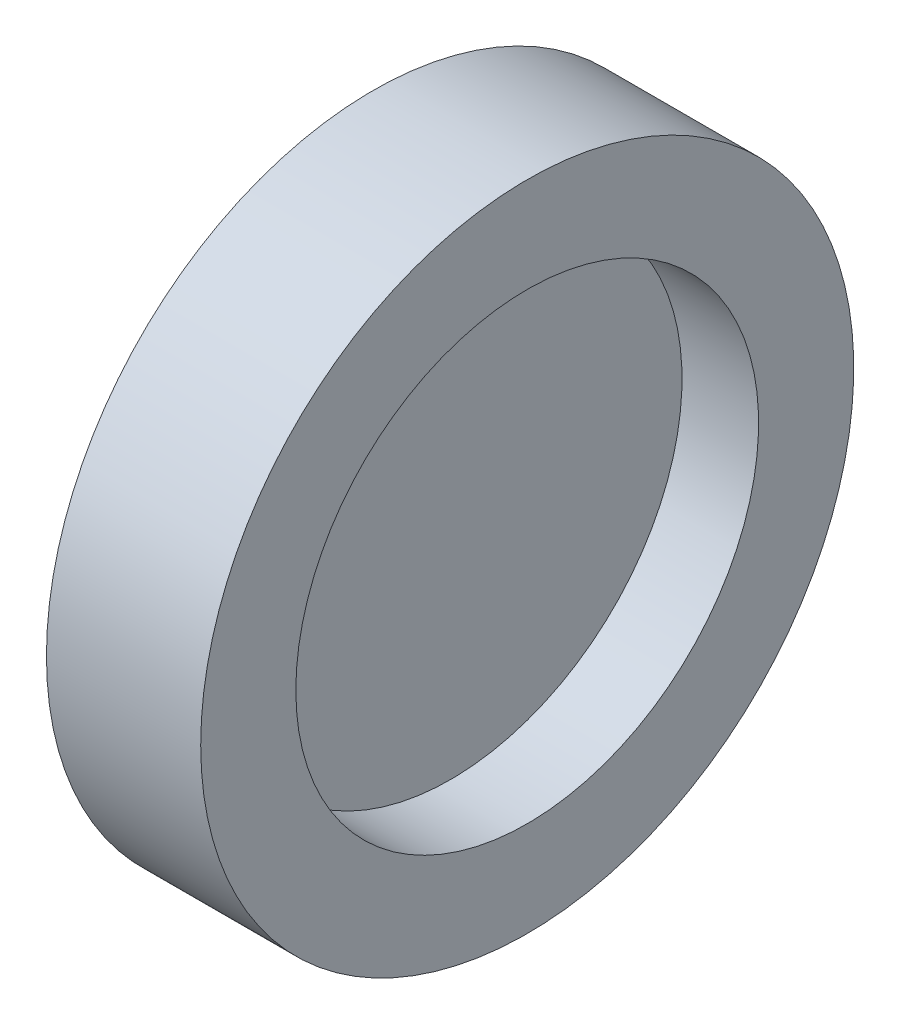
from build123d import *

# Parameters (mm, degrees)
SKETCH_1_W = 0.043
SKETCH_1_H = 9
SKETCH_4_W = 6
SKETCH_4_H = 3.7


with BuildPart() as part:
    # 草图1 → 旋转2 (revolve)
    with BuildSketch(Plane.XY, mode=Mode.PRIVATE) as revolve_2_sk:
        with Locations((0, 4.5)):
            Rectangle(SKETCH_1_W, SKETCH_1_H)
    revolve(revolve_2_sk.sketch.rotate(Axis((-0.0215, 0, 0), (1, 0, 0)), 90), axis=Axis((-0.0215, 0, 0), (1, 0, 0)))  # turned: the seam where the file's is

    # 草图4 → 旋转3 (revolve)
    with BuildSketch(Plane.XY, mode=Mode.PRIVATE) as revolve_3_sk:
        with Locations((0, 10.85)):
            Rectangle(SKETCH_4_W, SKETCH_4_H)
    revolve(revolve_3_sk.sketch.rotate(Axis((-1.614212419, 0, 0), (1, 0, 0)), 90), axis=Axis((-1.614212419, 0, 0), (1, 0, 0)))  # turned: the seam where the file's is


solid = part.part
